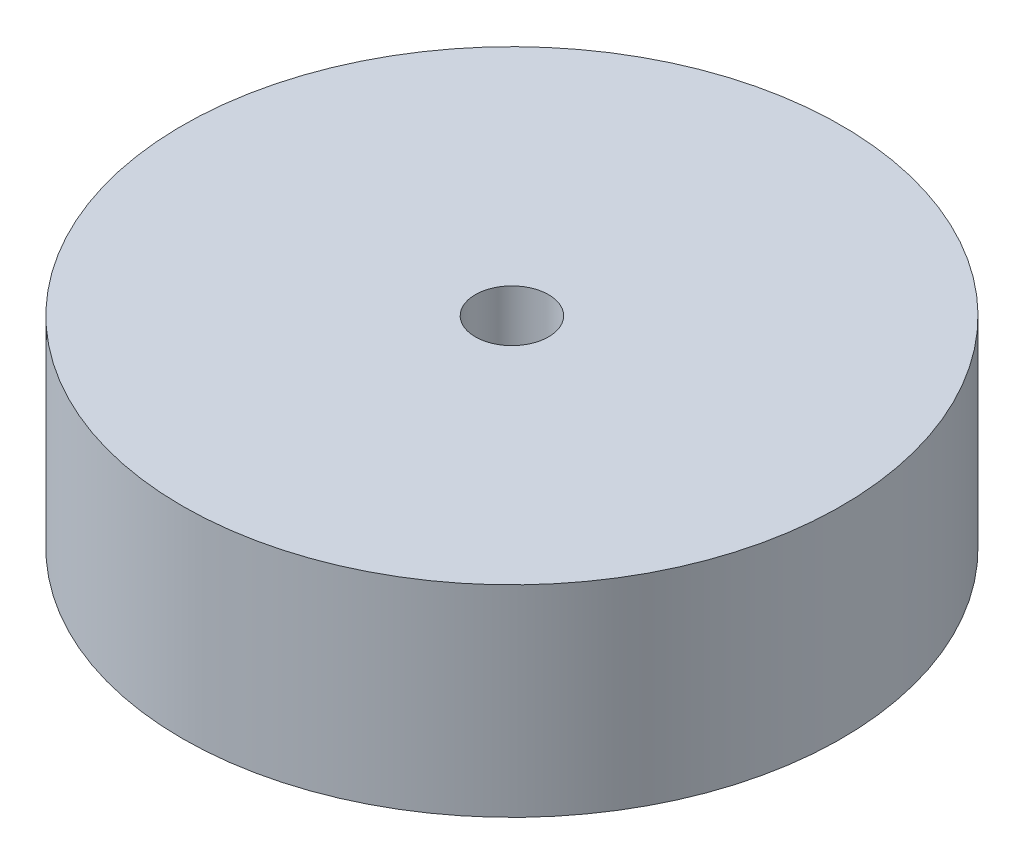
from build123d import *

# Parameters (mm, degrees)
SKETCH1_R           = 9
SKETCH1_R_2         = 2
SKETCH1_R_3         = 2.25
BOSS_EXTRUDE1_DEPTH = 2.5
SKETCH2_R           = 9
BOSS_EXTRUDE2_DEPTH = 3
SKETCH3_R           = 1
CUT_EXTRUDE1_DEPTH  = 6.5


with BuildPart() as part:
    # Sketch1 → Boss-Extrude1 (new body)
    with BuildSketch(Plane(origin=(0, 0, 0), x_dir=(1, 0, 0), z_dir=(0, 1, 0))):
        Circle(SKETCH1_R)
        with Locations((-4.763139721, -2.75)):
            Circle(SKETCH1_R_2, mode=Mode.SUBTRACT)
        with Locations((0, 5.5)):
            Circle(SKETCH1_R_2, mode=Mode.SUBTRACT)
        with Locations((4.763139721, -2.75)):
            Circle(SKETCH1_R_2, mode=Mode.SUBTRACT)
        Circle(SKETCH1_R_3, mode=Mode.SUBTRACT)
    extrude(amount=BOSS_EXTRUDE1_DEPTH)

    # Sketch2 → Boss-Extrude2 (add)
    with BuildSketch(Plane(origin=(0, 2.5, 0), x_dir=(1, 0, 0), z_dir=(0, 1, 0))):
        Circle(SKETCH2_R)
    extrude(amount=BOSS_EXTRUDE2_DEPTH)

    # Sketch3 → Cut-Extrude1 (cut, through all)
    with BuildSketch(Plane(origin=(0, 5.5, 0), x_dir=(1, 0, 0), z_dir=(0, 1, 0))):
        Circle(SKETCH3_R)
    extrude(amount=-CUT_EXTRUDE1_DEPTH, mode=Mode.SUBTRACT)


solid = part.part
